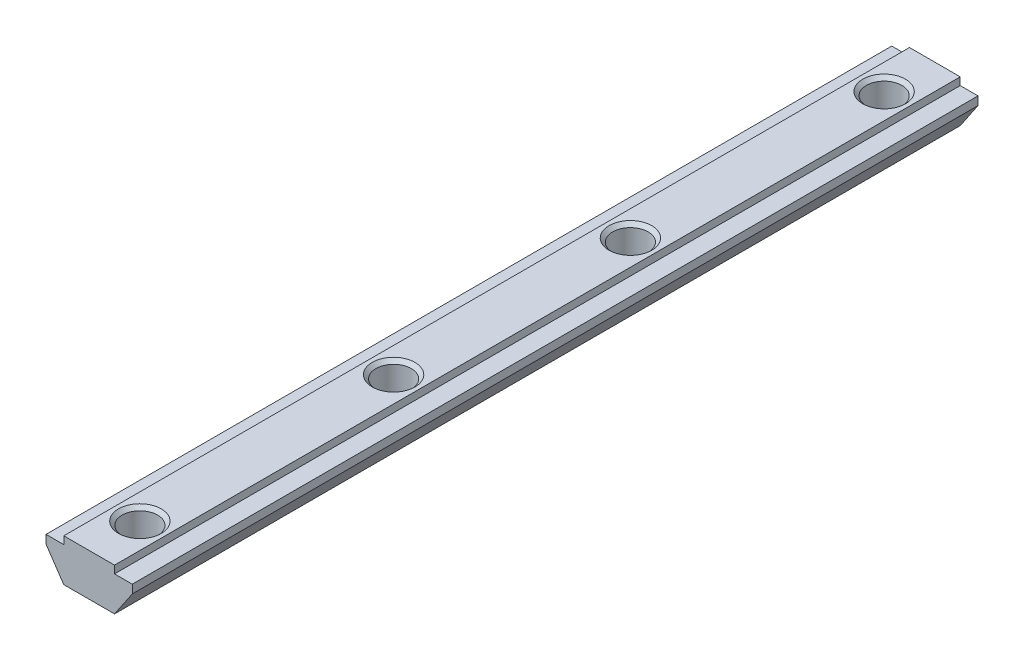
from build123d import *

# Parameters (mm, degrees)
EXTRUDE_1_DEPTH            = 50
HOLE_WIZARD_M51_AT_2_COUNT = 2
HOLE_WIZARD_M51_AT_2_PITCH = 30
HOLE_WIZARD_M51_AT_3_COUNT = 2
HOLE_WIZARD_M51_AT_3_PITCH = 58
HOLE_WIZARD_M51_AT_4_COUNT = 2
HOLE_WIZARD_M51_AT_4_PITCH = 88


with BuildPart() as part:
    # Эскиз1 → Бобышка-Вытянуть1 (new body, symmetric)
    with BuildSketch(Plane.XY):
        Polygon((3, 0), (-3, 0), (-3, -0.9), (-5.1, -0.9), (-5.1, -1.9), (-3, -5), (3, -5), (5.1, -1.9), (5.1, -0.9), (3, -0.9), align=None)
    extrude(amount=EXTRUDE_1_DEPTH, both=True)

    # Эскиз4 → Отверстие обработанное метчиком M51 (revolve, cut)
    with BuildSketch(Plane(origin=(0, 0, -44), x_dir=(0, 0, 1), z_dir=(1, 0, 0))):
        Polygon((0, 0), (0, 5), (2.525, 5), (2.1, 4.575), (2.1, 0.425), (2.525, 0), align=None)
    hole_wizard_m51 = revolve(axis=Axis((0, 6.35, -44), (0, -1, 0)), mode=Mode.SUBTRACT)

    # Отверстие обработанное метчиком M51 at 2: Отверстие обработанное метчиком M51 ×2
    with Locations(*[(0, 0, i * HOLE_WIZARD_M51_AT_2_PITCH) for i in range(1, HOLE_WIZARD_M51_AT_2_COUNT)]):
        add(hole_wizard_m51, mode=Mode.SUBTRACT)

    # Отверстие обработанное метчиком M51 at 3: Отверстие обработанное метчиком M51 ×2
    with Locations(*[(0, 0, i * HOLE_WIZARD_M51_AT_3_PITCH) for i in range(1, HOLE_WIZARD_M51_AT_3_COUNT)]):
        add(hole_wizard_m51, mode=Mode.SUBTRACT)

    # Отверстие обработанное метчиком M51 at 4: Отверстие обработанное метчиком M51 ×2
    with Locations(*[(0, 0, i * HOLE_WIZARD_M51_AT_4_PITCH) for i in range(1, HOLE_WIZARD_M51_AT_4_COUNT)]):
        add(hole_wizard_m51, mode=Mode.SUBTRACT)


solid = part.part
